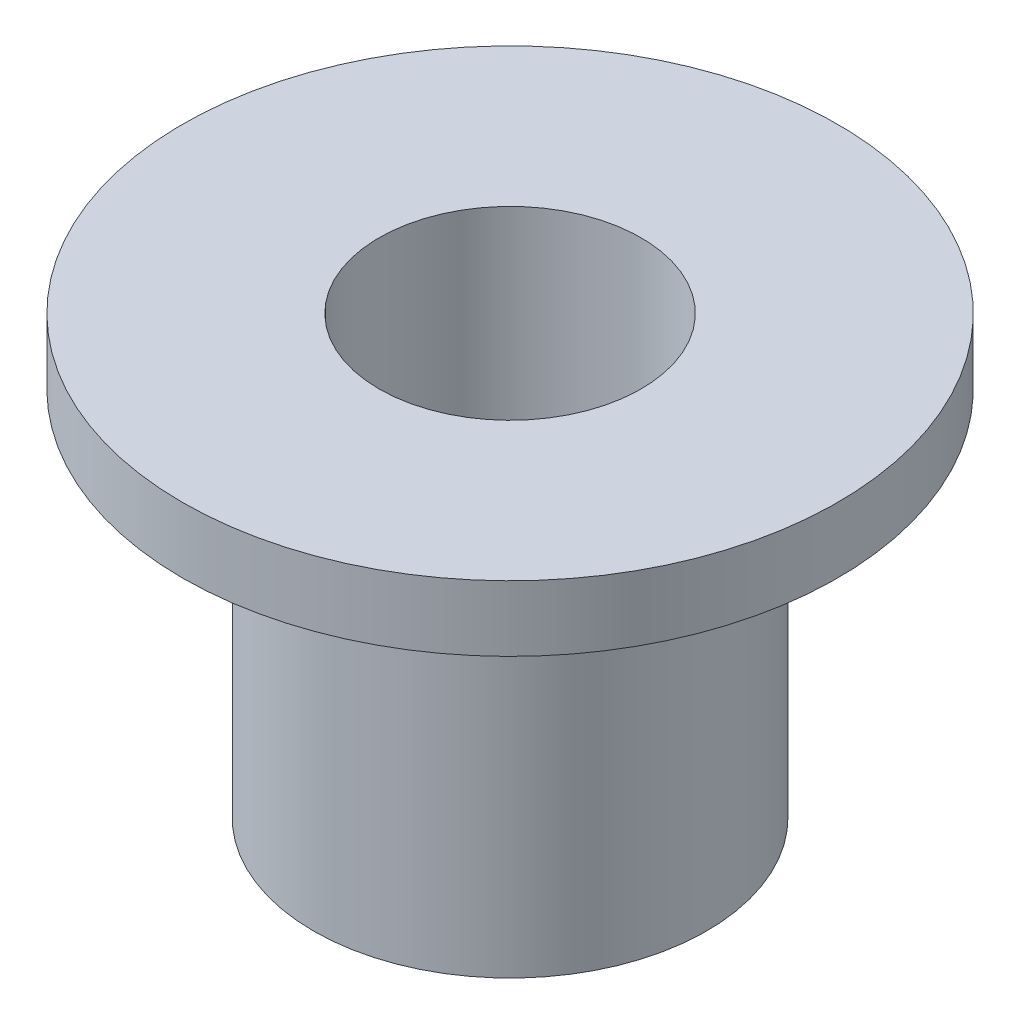
from build123d import *


with BuildPart() as part:
    # Esquisse1 → Révolution1 (revolve)
    with BuildSketch(Plane.XY):
        Polygon((-3.75, 5), (-1.5, 5), (-1.5, 0), (-2.25, 0), (-2.25, 4.25), (-3.75, 4.25), align=None)
    revolve(axis=Axis((0, 5, 0), (0, -1, 0)))


solid = part.part
